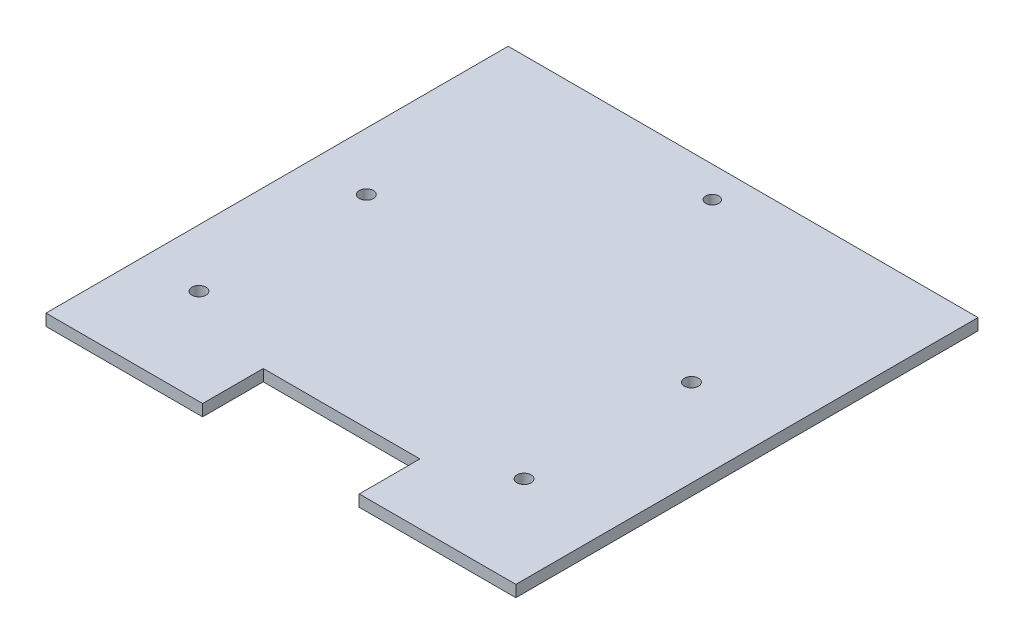
from build123d import *

# Parameters (mm, degrees)
SKETCH1_W           = 193.68
SKETCH1_H           = 190.5
BOSS_EXTRUDE1_DEPTH = 4.78
SKETCH2_R           = 2.6797
CUT_EXTRUDE1_DEPTH  = 5.78
CUT_EXTRUDE2_DEPTH  = 5.78
SKETCH4_R           = 2.893699953
CUT_EXTRUDE3_DEPTH  = 5.78


with BuildPart() as part:
    # Sketch1 → Boss-Extrude1 (new body)
    with BuildSketch(Plane(origin=(0, 0, 0), x_dir=(1, 0, 0), z_dir=(0, 1, 0))):
        Rectangle(SKETCH1_W, SKETCH1_H)
    extrude(amount=BOSS_EXTRUDE1_DEPTH)

    # Sketch2 → Cut-Extrude1 (cut, through all)
    with BuildSketch(Plane(origin=(0, 4.78, 0), x_dir=(1, 0, 0), z_dir=(0, 1, 0))):
        with Locations((0, 82.55)):
            Circle(SKETCH2_R)
    extrude(amount=-CUT_EXTRUDE1_DEPTH, mode=Mode.SUBTRACT)

    # Sketch3 → Cut-Extrude2 (cut, through all)
    with BuildSketch(Plane(origin=(0, 4.78, 0), x_dir=(1, 0, 0), z_dir=(0, 1, 0))):
        Polygon((0, -95.25), (-32.28, -95.25), (-32.28, -70.249999962), (32.28, -70.249999962), (32.28, -95.25), align=None)
    extrude(amount=-CUT_EXTRUDE2_DEPTH, mode=Mode.SUBTRACT)

    # Sketch4 → Cut-Extrude3 (cut, through all)
    with BuildSketch(Plane(origin=(0, 4.78, 0), x_dir=(1, 0, 0), z_dir=(0, 1, 0))):
        with Locations((-73.14, -55.899999962)):
            Circle(SKETCH4_R)
        with Locations((-73.14, 13.100000038)):
            Circle(SKETCH4_R)
        with Locations((60.86, 13.100000038)):
            Circle(SKETCH4_R)
        with Locations((60.86, -55.899999962)):
            Circle(SKETCH4_R)
    extrude(amount=-CUT_EXTRUDE3_DEPTH, mode=Mode.SUBTRACT)


solid = part.part
